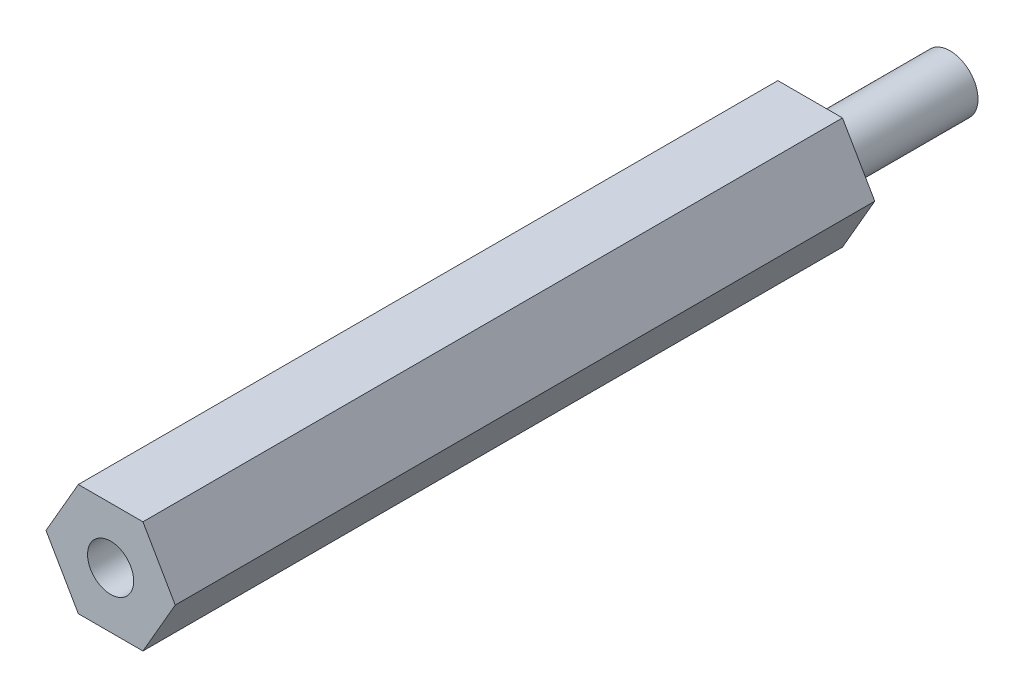
from build123d import *

# Parameters (mm, degrees)
EXTRUDE_1_DEPTH = 50
SKETCH_4_R      = 2
EXTRUDE_2_DEPTH = 10
M4X0_7_1_D      = 3.3
M4X0_7_1_DEPTH  = 10.1
M4X0_7_1_TIP    = 0.991420021


with BuildPart() as part:
    # 草圖1 → 填料-伸長1 (new body)
    with BuildSketch(Plane.XY):
        Polygon((-2.309401077, 4), (-4.618802154, 0), (-2.309401077, -4), (2.309401077, -4), (4.618802154, 0), (2.309401077, 4), align=None)
    extrude(amount=EXTRUDE_1_DEPTH)

    # 草圖4 → 填料-伸長2 (add)
    with BuildSketch(Plane(origin=(0, 0, 0), x_dir=(-1, 0, 0), z_dir=(0, 0, -1))):
        Circle(SKETCH_4_R)
    extrude(amount=EXTRUDE_2_DEPTH)

    # M4x0.7 螺紋孔1
    with Locations(Plane.XY.offset(50)):
        with Locations((0, 0)):
            Hole(M4X0_7_1_D / 2, depth=M4X0_7_1_DEPTH)
            with Locations((0, 0, -(M4X0_7_1_DEPTH + M4X0_7_1_TIP / 2))):  # 118° drill point
                Cone(0, M4X0_7_1_D / 2, M4X0_7_1_TIP, mode=Mode.SUBTRACT)


solid = part.part
